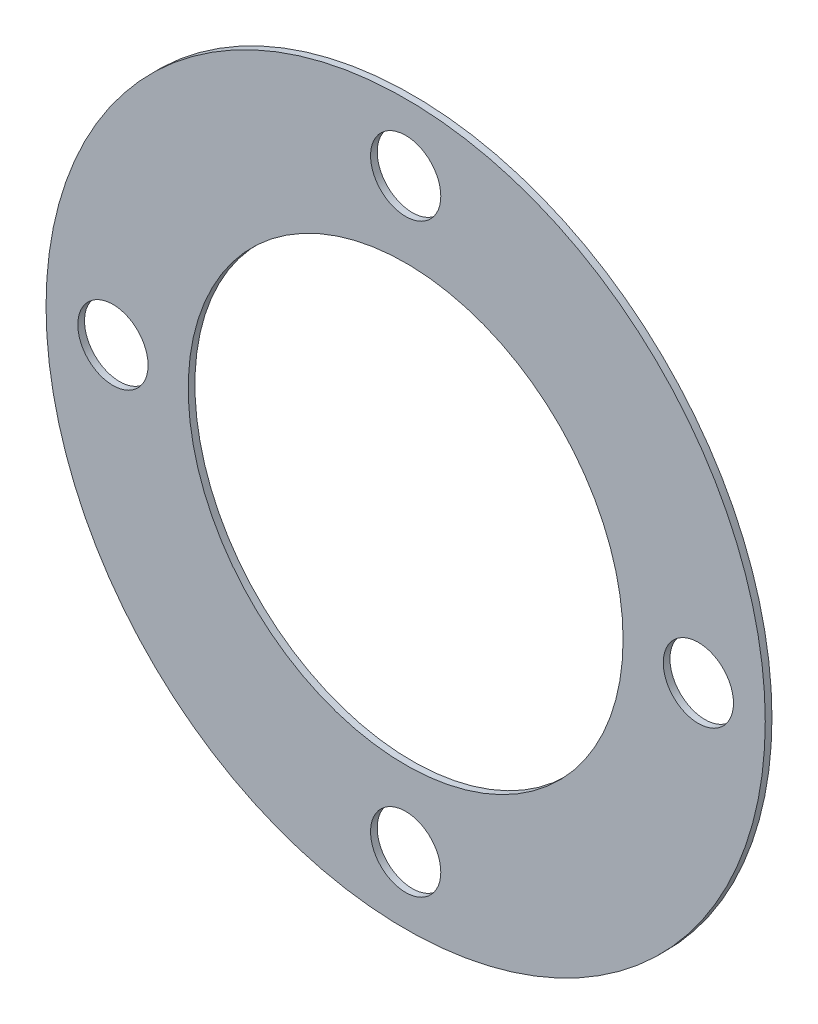
from build123d import *

# Parameters (mm, degrees)
SKETCH1_R           = 2.1
SKETCH1_R_2         = 13
BOSS_EXTRUDE1_DEPTH = 0.4
BOSS_EXTRUDE2_DEPTH = 0.4


with BuildPart() as part:
    # Sketch1 → Boss-Extrude1 (new body)
    with BuildSketch(Plane(origin=(0, 0, 0), x_dir=(0, 1, 0), z_dir=(0, 0, 1))):
        with BuildLine():
            ThreePointArc((21.242857143, -3.31527079), (21.435617889, -1.662614121), (21.5, 0))
            ThreePointArc((21.5, 0), (21.435617889, 1.662614121), (21.242857143, 3.31527079))
            ThreePointArc((21.242857143, 3.31527079), (19.220493395, 4.694667451), (16.785714286, 4.948716593))
            ThreePointArc((16.785714286, 4.948716593), (12.374368671, 12.374368671), (4.948716593, 16.785714286))
            ThreePointArc((4.948716593, 16.785714286), (4.694667451, 19.220493395), (3.31527079, 21.242857143))
            ThreePointArc((3.31527079, 21.242857143), (0, 21.5), (-3.31527079, 21.242857143))
            ThreePointArc((-3.31527079, 21.242857143), (-4.694667451, 19.220493395), (-4.948716593, 16.785714286))
            ThreePointArc((-4.948716593, 16.785714286), (-12.374368671, 12.374368671), (-16.785714286, 4.948716593))
            ThreePointArc((-16.785714286, 4.948716593), (-19.220493395, 4.694667451), (-21.242857143, 3.31527079))
            ThreePointArc((-21.242857143, 3.31527079), (-21.5, 0), (-21.242857143, -3.31527079))
            ThreePointArc((-21.242857143, -3.31527079), (-19.220493395, -4.694667451), (-16.785714286, -4.948716593))
            ThreePointArc((-16.785714286, -4.948716593), (-12.374368671, -12.374368671), (-4.948716593, -16.785714286))
            ThreePointArc((-4.948716593, -16.785714286), (-4.694667451, -19.220493395), (-3.31527079, -21.242857143))
            ThreePointArc((-3.31527079, -21.242857143), (0, -21.5), (3.31527079, -21.242857143))
            ThreePointArc((3.31527079, -21.242857143), (4.694667451, -19.220493395), (4.948716593, -16.785714286))
            ThreePointArc((4.948716593, -16.785714286), (12.374368671, -12.374368671), (16.785714286, -4.948716593))
            ThreePointArc((16.785714286, -4.948716593), (19.220493395, -4.694667451), (21.242857143, -3.31527079))
        make_face()
        with Locations((0, -17.5)):
            Circle(SKETCH1_R, mode=Mode.SUBTRACT)
        Circle(SKETCH1_R_2, mode=Mode.SUBTRACT)
        with Locations((17.5, 0)):
            Circle(SKETCH1_R, mode=Mode.SUBTRACT)
        with Locations((-17.5, 0)):
            Circle(SKETCH1_R, mode=Mode.SUBTRACT)
        with Locations((0, 17.5)):
            Circle(SKETCH1_R, mode=Mode.SUBTRACT)
    extrude(amount=BOSS_EXTRUDE1_DEPTH)

    # Sketch1_4 → Boss-Extrude2 (add)
    with BuildSketch(Plane(origin=(0, 0, 0), x_dir=(0, 1, 0), z_dir=(0, 0, 1))):
        with BuildLine():
            ThreePointArc((16.785714286, 4.948716593), (19.220493395, 4.694667451), (21.242857143, 3.31527079))
            ThreePointArc((21.242857143, 3.31527079), (15.202795796, 15.202795796), (3.31527079, 21.242857143))
            ThreePointArc((3.31527079, 21.242857143), (4.694667451, 19.220493395), (4.948716593, 16.785714286))
            ThreePointArc((4.948716593, 16.785714286), (12.374368671, 12.374368671), (16.785714286, 4.948716593))
        make_face()
        with BuildLine():
            ThreePointArc((3.31527079, -21.242857143), (15.202795796, -15.202795796), (21.242857143, -3.31527079))
            ThreePointArc((21.242857143, -3.31527079), (19.220493395, -4.694667451), (16.785714286, -4.948716593))
            ThreePointArc((16.785714286, -4.948716593), (12.374368671, -12.374368671), (4.948716593, -16.785714286))
            ThreePointArc((4.948716593, -16.785714286), (4.694667451, -19.220493395), (3.31527079, -21.242857143))
        make_face()
        with BuildLine():
            ThreePointArc((-4.948716593, 16.785714286), (-4.694667451, 19.220493395), (-3.31527079, 21.242857143))
            ThreePointArc((-3.31527079, 21.242857143), (-15.202795796, 15.202795796), (-21.242857143, 3.31527079))
            ThreePointArc((-21.242857143, 3.31527079), (-19.220493395, 4.694667451), (-16.785714286, 4.948716593))
            ThreePointArc((-16.785714286, 4.948716593), (-12.374368671, 12.374368671), (-4.948716593, 16.785714286))
        make_face()
        with BuildLine():
            ThreePointArc((-21.242857143, -3.31527079), (-15.202795796, -15.202795796), (-3.31527079, -21.242857143))
            ThreePointArc((-3.31527079, -21.242857143), (-4.694667451, -19.220493395), (-4.948716593, -16.785714286))
            ThreePointArc((-4.948716593, -16.785714286), (-12.374368671, -12.374368671), (-16.785714286, -4.948716593))
            ThreePointArc((-16.785714286, -4.948716593), (-19.220493395, -4.694667451), (-21.242857143, -3.31527079))
        make_face()
    extrude(amount=BOSS_EXTRUDE2_DEPTH)


solid = part.part
